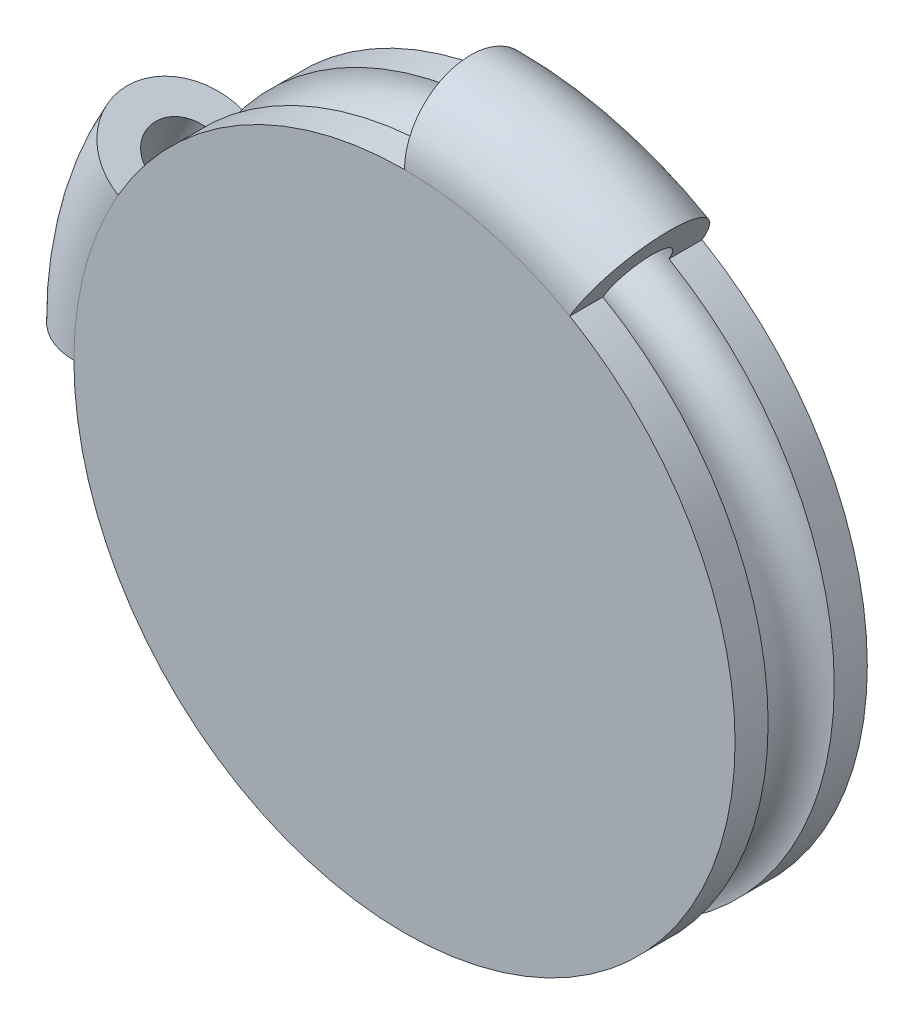
from build123d import *

# Parameters (mm, degrees)
ESQUISSE1_R                             = 10
BOSS_EXTRU_1_DEPTH                      = 2
ESQUISSE4_R                             = 2
R_VOLUTION1_ANGLE                       = 120
ESQUISSE2_R                             = 1
ENL_VEMENT_DE_MATI_RE_R_VOLUTION2_ANGLE = 60


with BuildPart() as part:
    # Esquisse1 → Boss.-Extru.1 (new body, symmetric)
    with BuildSketch(Plane.XY):
        Circle(ESQUISSE1_R)
    extrude(amount=BOSS_EXTRU_1_DEPTH, both=True)

    # Esquisse4 → Révolution1 (revolve)
    with BuildSketch(Plane(origin=(0, 0, 0), x_dir=(1, 0, 0), z_dir=(0, 1, 0))):
        with Locations((-10, 0)):
            Circle(ESQUISSE4_R)
    revolve(axis=Axis((0, 0, 2), (0, 0, -1)), revolution_arc=R_VOLUTION1_ANGLE)

    # Esquisse2 → Enlèvement de matière-Révolution1 (revolve, cut)
    with BuildSketch(Plane(origin=(0, 0, 0), x_dir=(0, 0, -1), z_dir=(1, 0, 0))):
        with Locations((0, 10)):
            Circle(ESQUISSE2_R)
    revolve(axis=Axis((0, 0, -8.634448203), (0, 0, 1)), mode=Mode.SUBTRACT)

    # Esquisse6 → Enlèvement de matière-Révolution2 (revolve, cut)
    with BuildSketch(Plane(origin=(0, 0, 0), x_dir=(0, 0, -1), z_dir=(1, 0, 0))):
        with BuildLine():
            Line((-2, 10), (-1, 10))
            ThreePointArc((-1, 10), (0, 11), (1, 10))
            Line((1, 10), (2, 10))
            ThreePointArc((2, 10), (0, 12), (-2, 10))
        make_face()
    revolve(axis=Axis((0, 0, 0), (0, 0, 1)), revolution_arc=ENL_VEMENT_DE_MATI_RE_R_VOLUTION2_ANGLE, mode=Mode.SUBTRACT)


solid = part.part
